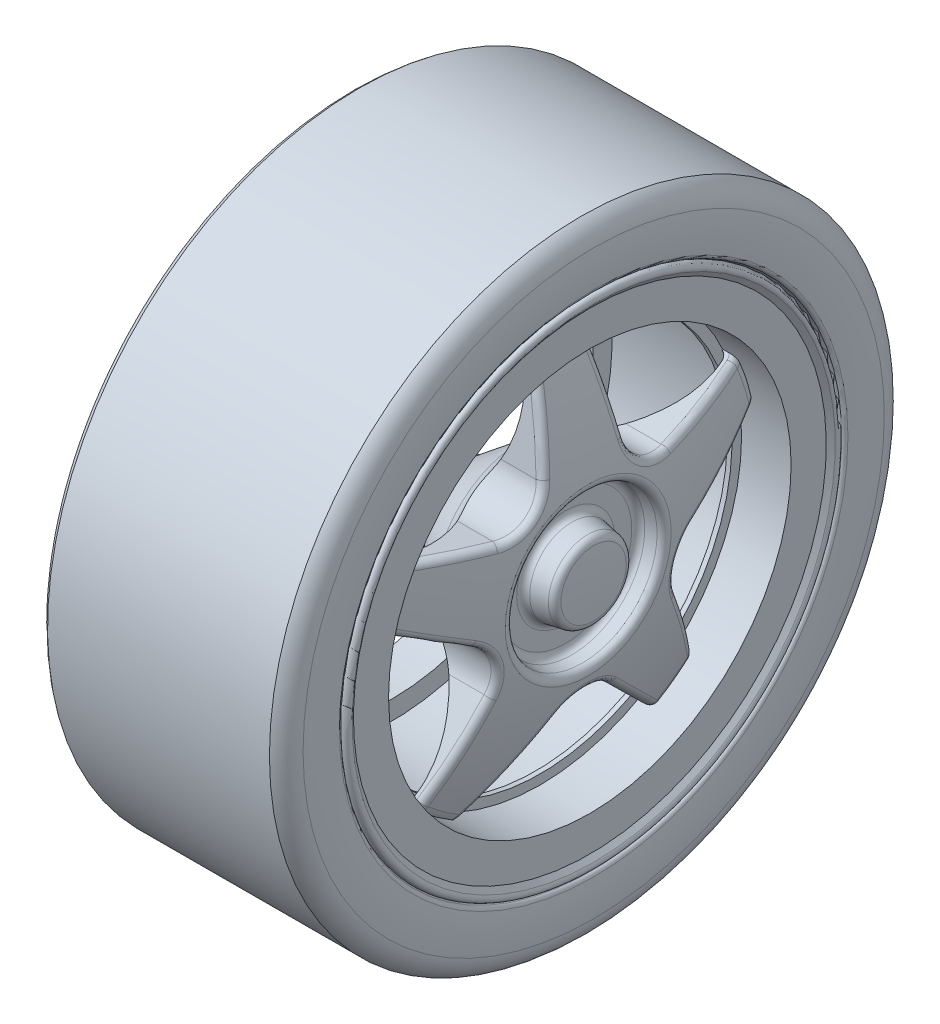
from build123d import *

# Parameters (mm, degrees)
CORTAR_EXTRUIR1_START    = 28.999999999999996
CORTAR_EXTRUIR1_DEPTH    = 28.999999999999996
MATRIZC1_COUNT           = 5
REDONDEO1_R              = 0.75
REDONDEO2_R              = 0.75
CORTAR_EXTRUIR2_DEPTH    = 10
CUT_EXTRUDE_4_DEPTH      = 50.33558566795354
CUT_EXTRUDE_4_DEPTH_BACK = 50.33558566795354
SKETCH_1_R               = 41.136292346000886
SKETCH_1_R_2             = 32.5


with BuildPart() as part:
    # Croquis1 → Revoluci_n1 (revolve)
    with BuildSketch(Plane.XY):
        with BuildLine():
            Line((-10.499999999999996, 24.999999999999996), (-12.26470588235294, 25.941176470588232))
            ThreePointArc((-12.26470588235294, 25.941176470588232), (-12.879791858685124, 25.82520477253032), (-12.89969812418834, 25.199597920246344))
            Line((-12.89969812418834, 25.199597920246344), (-12.499999999999996, 24.667782059947733))
            Line((-12.499999999999996, 24.667782059947733), (-12.499999999999996, 20.999999999999996))
            Line((-12.499999999999996, 20.999999999999996), (6.832217940052267, 20.999999999999996))
            Line((6.832217940052267, 20.999999999999996), (8.832217940052265, 20.999999999999996))
            Line((8.832217940052265, 20.999999999999996), (12.500000000000004, 20.999999999999996))
            Line((12.500000000000004, 20.999999999999996), (12.500000000000004, 24.667782059947736))
            Line((12.500000000000004, 24.667782059947736), (12.899698124188344, 25.199597920246347))
            ThreePointArc((12.899698124188342, 25.199597920246347), (12.879791858685127, 25.825204772530324), (12.264705882352946, 25.941176470588236))
            Line((12.264705882352946, 25.941176470588236), (10.500000000000002, 24.999999999999996))
            Line((10.500000000000004, 24.999999999999996), (-10.499999999999996, 24.999999999999996))
        make_face()
    revolve(axis=Axis((13.000000000000005, 0, 0), (-1, -1.2e-16, 0)))


with BuildPart() as body_2:
    # Croquis1_3 → Revoluci_n2 (revolve)
    with BuildSketch(Plane.XY):
        with BuildLine():
            Line((8.832217940052265, 20.999999999999996), (6.832217940052267, 20.999999999999996))
            ThreePointArc((6.832217940052267, 20.999999999999996), (7.678536500553859, 20.738444546255707), (8.229709414249841, 20.044993192200682))
            ThreePointArc((8.229709414249843, 20.04499319220068), (7.643887824469812, 11.750728907281768), (0.8552681226072676, 6.949411431149043))
            Line((0.8552681226072671, 6.949411431149044), (-16.00000000000001, 4))
            Line((-16.00000000000001, 4), (-16.000000000000007, -3.55e-15))
            Line((-16.000000000000007, -3.55e-15), (13.000000000000005, 0))
            ThreePointArc((13, -1.1e-16), (12.964337478538141, 2.001270604482038), (12.857395198343092, 4))
            Line((12.857395198343093, 4), (10.000000000000002, 4.5))
            Line((10.000000000000002, 4.5), (9.999999999999998, 7.5))
            Line((9.999999999999998, 7.5), (12.437899090853024, 7.926594664305908))
            ThreePointArc((12.43789909085303, 7.926594664305907), (11.159269913999424, 14.261864726586808), (9.16137039704823, 20.40832198700114))
            ThreePointArc((9.161370397048223, 20.40832198700114), (9.016917225250367, 20.715355517227323), (8.832217940052265, 20.999999999999996))
        make_face()
    revolve(axis=Axis((13.000000000000005, 0, 0), (-1, -1.2e-16, 0)))

    # Croquis2 → Cortar-Extruir1 (cut)
    with BuildSketch(Plane(origin=(0, 0, 0), x_dir=(0, 0, -1), z_dir=(1, 0, 0)).offset(CORTAR_EXTRUIR1_START)):
        with BuildLine():
            ThreePointArc((-2.559211720763677, 20.843474647196086), (-12.343490298141935, 16.989356881873892), (-19.032482471529132, 8.874942871418174))
            Line((-19.032482471529132, 8.874942871418174), (-8.788959816618782, 7.312581296013566))
            ThreePointArc((-8.788959816618782, 7.312581296013567), (-5.834705949164168, 8.030783779695161), (-4.238740146298037, 10.618509398268122))
            Line((-4.238740146298038, 10.618509398268122), (-2.5592117207636766, 20.843474647196086))
        make_face()
    cortar_extruir1 = extrude(amount=-CORTAR_EXTRUIR1_DEPTH, mode=Mode.SUBTRACT)

    # MatrizC1: Cortar-Extruir1 ×5 about axis
    matrizc1_axis = Axis((0.8552681226072674, -1.49e-15, 0), (-1, -1.2e-16, 0))
    for i in range(1, MATRIZC1_COUNT):
        add(cortar_extruir1.rotate(matrizc1_axis, i * 360 / MATRIZC1_COUNT), mode=Mode.SUBTRACT)


with BuildPart() as cortar_revoluci_n1_tool:
    # Croquis3 → Cortar-Revoluci_n1 (revolve)
    with BuildSketch(Plane.XY):
        Polygon((7.332217940052267, 19.499999999999996), (7.332217940052267, 22.999999999999993), (-8.167782059947733, 22.999999999999993), (-8.167782059947733, 20.99999999999999), (6.832217940052267, 20.999999999999996), (6.832217940052267, 19.499999999999996), align=None)
    revolve(axis=Axis((0.8552681226072674, -1.49e-15, 0), (-1, -1.2e-16, 0)))


with BuildPart() as part_1:
    add(part.part)

    # Cortar-Revoluci_n1: cut by cortar_revoluci_n1_tool
    add(cortar_revoluci_n1_tool.part, mode=Mode.SUBTRACT)

    # Croquis4 → Revoluci_n3 (revolve)
    with BuildSketch(Plane.XY):
        with BuildLine():
            Line((7.332217940052267, 22.999999999999993), (6.832217940052267, 22.999999999999993))
            Line((6.832217940052267, 22.999999999999993), (5.332217940052269, 22.999999999999996))
            ThreePointArc((5.332217940052269, 22.999999999999996), (6.39287811183209, 22.56066017177982), (6.832217940052267, 21.499999999999996))
            Line((6.832217940052267, 21.499999999999996), (6.832217940052267, 19.999999999999996))
            Line((6.832217940052267, 19.999999999999996), (7.332217940052267, 19.999999999999996))
            Line((7.332217940052267, 19.999999999999996), (7.332217940052267, 22.999999999999993))
        make_face()
    revolve(axis=Axis((0.8552681226072674, -1.49e-15, 0), (-1, -1.2e-16, 0)))


with BuildPart() as body_2_1:
    add(body_2.part)

    # Cortar-Revoluci_n1: cut by cortar_revoluci_n1_tool
    add(cortar_revoluci_n1_tool.part, mode=Mode.SUBTRACT)

    # Redondeo1
    redondeo1_edges = [body_2_1.edges().sort_by_distance(p)[0] for p in [
        (9.01739035256138, 20.549741045647362, 2.6074597021822328),
        (9.017390352561383, 8.830060753846865, 18.738215769518757),
        (9.017390352561382, 8.83006075384687, -18.738215769518753),
        (9.017390352561382, 20.549741045647362, -2.6074597021822283),
        (9.017390352561383, -15.092463377043474, -14.188313936274096),
        (9.017390352561383, 3.870377672372008, -20.349714489763056),
        (9.01739035256139, -18.157716094822757, 9.969355513847557),
        (9.017390352561385, -18.157716094822757, -9.969355513847567),
        (9.017390352561385, -15.092463377043478, 14.188313936274083),
        (9.01739035256138, 3.870377672372001, 20.34971448976306),
        (12.115914274162746, -3.0674864475193093, 9.440752540118355),
        (10.713468801645433, 1.5145168386754992, 15.790780090462366),
        (10.713468801645426, 8.056317798611875, 13.665220109743698),
        (12.115914274162725, 8.030783779711285, 5.834705949145336),
        (10.71346880164542, 15.485935743835698, 3.439228293929378),
        (10.71346880164542, 15.485935743835705, -3.4392282939293746),
        (12.115914274162726, 8.030783779682231, -5.834705949185325),
        (10.713468801645433, 8.056317798611877, -13.665220109743679),
        (10.713468801645433, 1.514516838675502, -15.79078009046236),
        (12.115914274162744, -3.067486447566318, -9.440752540103086),
        (10.713468801645455, -10.506857520122946, -11.884798785499576),
        (10.713468801645462, -14.549912861000298, -6.320010510851561),
        (12.115914274162773, -9.926594664307892, 2.47129e-11),
        (10.713468801645462, -14.549912861000305, 6.320010510851561),
        (10.713468801645455, -10.50685752012294, 11.884798785499566),
        (12.857395198343095, -4, -4.9e-16),
        (10.000000000000002, -4.5, -5.5e-16),
        (10.000000000000002, -7.5, -4.25e-15),
    ]]
    fillet(redondeo1_edges, radius=REDONDEO1_R)

    # Croquis6 → Cortar-Revoluci_n4 (revolve, cut)
    with BuildSketch(Plane.XY):
        with BuildLine():
            Line((-16.00000000000001, 4), (-1.0000000000000113, 4))
            Line((-1.0000000000000113, 4), (5.19865531394286, 8.892777087963003))
            ThreePointArc((5.19865531394286, 8.892777087963003), (3.1478175399954633, 7.6509836778349705), (0.8552681226072709, 6.9494114311490165))
            Line((0.8552681226072709, 6.9494114311490165), (-16.00000000000001, 4))
        make_face()
    revolve(axis=Axis((0.8552681226072674, -1.49e-15, 0), (-1, -1.2e-16, 0)), mode=Mode.SUBTRACT)

    # Redondeo2
    redondeo2_edges = [body_2_1.edges().sort_by_distance(p)[0] for p in [
        (12.43789909085303, -7.926594664305908, -9.7e-16),
    ]]
    fillet(redondeo2_edges, radius=REDONDEO2_R)

    # Croquis8 → Cortar-Extruir2 (cut)
    with BuildSketch(Plane.ZY.offset(16.000000000000007)):
        with BuildLine():
            Line((-1.7999999999999998, 2.012461179749811), (-1.7999999999999998, -2.012461179749811))
            ThreePointArc((-1.7999999999999998, -2.012461179749811), (3.8e-16, -2.6999999999999966), (1.8000000000000003, -2.012461179749811))
            Line((1.8000000000000003, -2.012461179749811), (1.8000000000000003, 2.012461179749811))
            ThreePointArc((1.8000000000000003, 2.012461179749811), (3.8e-16, 2.6999999999999993), (-1.7999999999999998, 2.012461179749811))
        make_face()
    extrude(amount=-CORTAR_EXTRUIR2_DEPTH, mode=Mode.SUBTRACT)


with BuildPart() as body_3:
    # Croquis7 → Revoluci_n4 (revolve)
    with BuildSketch(Plane.XY):
        with BuildLine():
            Line((12.638075261313753, 26.140306806033998), (10.500000000000002, 24.999999999999996))
            Line((10.500000000000002, 24.999999999999996), (-10.499999999999996, 24.999999999999996))
            Line((-10.499999999999996, 24.999999999999996), (-12.638075261313748, 26.140306806033994))
            ThreePointArc((-12.638075261313748, 26.140306806033994), (-12.817364623189448, 26.30198276051036), (-12.900000000000002, 26.528820112013626))
            ThreePointArc((-12.900000000000002, 26.528820112013626), (-13, 28.42239954983263), (-12.899999999999999, 30.31597898765163))
            ThreePointArc((-12.899999999999999, 30.31597898765163), (-11.900593556448989, 32.25035868868076), (-9.856188935408268, 32.999389938116956))
            ThreePointArc((-9.856188935408268, 32.999389938116956), (2.993e-14, 32.899999999999864), (9.856188935408268, 32.999389938116956))
            ThreePointArc((9.856188935408268, 32.999389938116956), (11.900593556448985, 32.25035868868076), (12.899999999999997, 30.31597898765164))
            ThreePointArc((12.899999999999997, 30.31597898765164), (13.000000000000007, 28.422399549832633), (12.900000000000007, 26.528820112013626))
            ThreePointArc((12.900000000000007, 26.528820112013626), (12.817364623189453, 26.30198276051036), (12.638075261313753, 26.140306806033998))
        make_face()
    revolve(axis=Axis((13.000000000000005, 0, 0), (-1, -1.2e-16, 0)))

    # Sketch 1 → Cut-Extrude 4 (cut, two sides: drawn at the far end of the back side and taken through both)
    with BuildSketch(Plane(origin=(0, 0, 0), x_dir=(0, 0, -1), z_dir=(1, 0, 0)).offset(-CUT_EXTRUDE_4_DEPTH_BACK)):
        Circle(SKETCH_1_R)
        Circle(SKETCH_1_R_2, mode=Mode.SUBTRACT)
    extrude(amount=CUT_EXTRUDE_4_DEPTH + CUT_EXTRUDE_4_DEPTH_BACK, mode=Mode.SUBTRACT)


solid = Compound([part_1.part, body_2_1.part, body_3.part])
